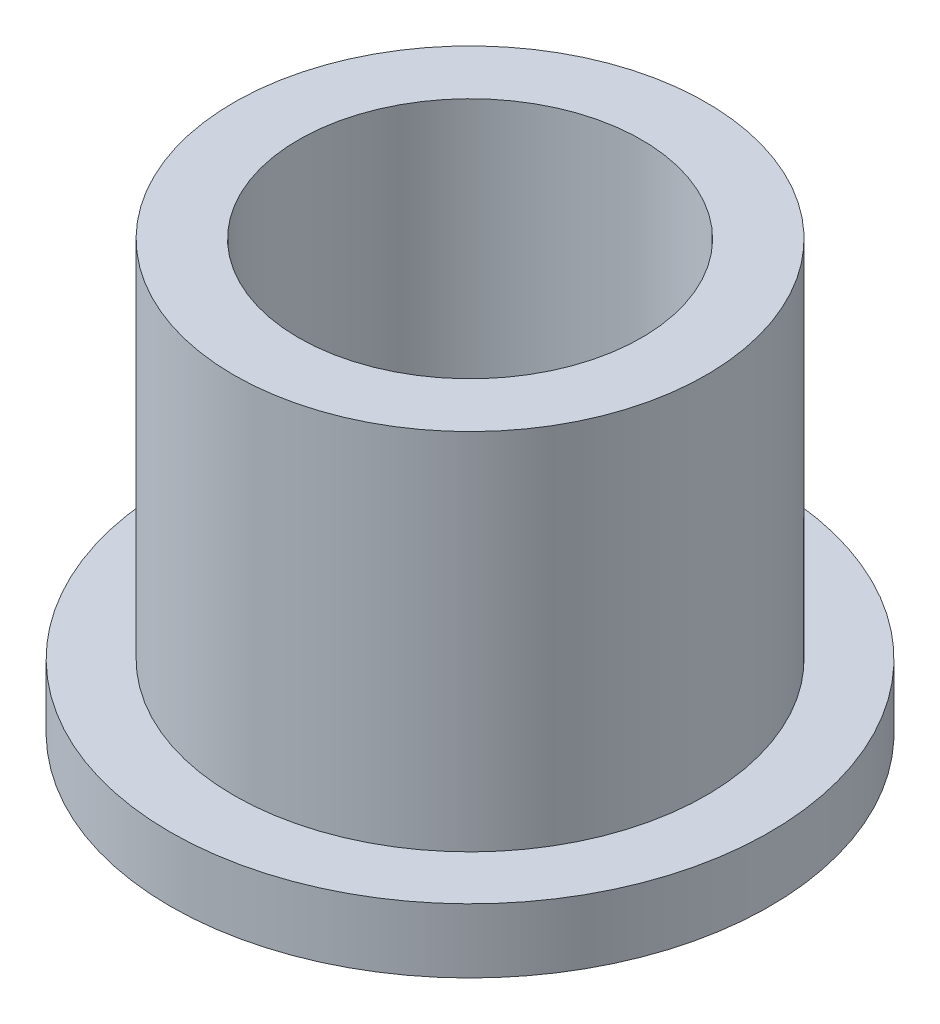
from build123d import *

# Parameters (mm, degrees)
SKETCH2_R           = 5.515
SKETCH2_R_2         = 4.005
BOSS_EXTRUDE1_DEPTH = 10
SKETCH3_R           = 7
SKETCH3_R_2         = 5.515
BOSS_EXTRUDE2_DEPTH = 1.5


with BuildPart() as part:
    # Sketch2 → Boss-Extrude1 (new body)
    with BuildSketch(Plane(origin=(0, 0, 0), x_dir=(1, 0, 0), z_dir=(0, 1, 0))):
        Circle(SKETCH2_R)
        Circle(SKETCH2_R_2, mode=Mode.SUBTRACT)
    extrude(amount=BOSS_EXTRUDE1_DEPTH)

    # Sketch3 → Boss-Extrude2 (add)
    with BuildSketch(Plane(origin=(0, 0, 0), x_dir=(1, 0, 0), z_dir=(0, 1, 0))):
        Circle(SKETCH3_R)
        Circle(SKETCH3_R_2, mode=Mode.SUBTRACT)
    extrude(amount=BOSS_EXTRUDE2_DEPTH)


solid = part.part
